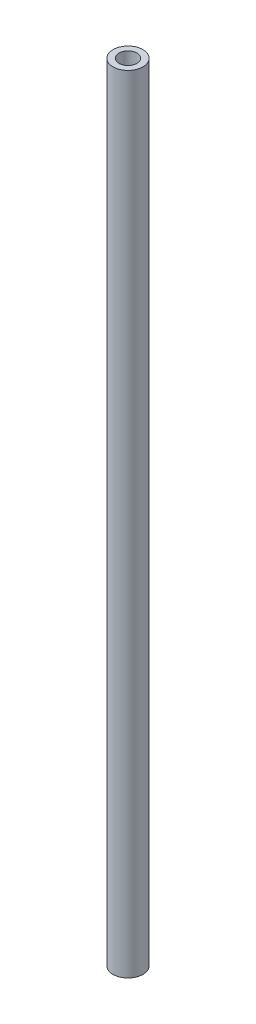
from build123d import *

# Parameters (mm, degrees)
SKETCH1_R           = 2
SKETCH1_R_2         = 1.2
BOSS_EXTRUDE1_DEPTH = 105


with BuildPart() as part:
    # Sketch1 → Boss-Extrude1 (new body)
    with BuildSketch(Plane(origin=(0, 0, 0), x_dir=(1, 0, 0), z_dir=(0, 1, 0))):
        Circle(SKETCH1_R)
        Circle(SKETCH1_R_2, mode=Mode.SUBTRACT)
    extrude(amount=BOSS_EXTRUDE1_DEPTH)


solid = part.part
